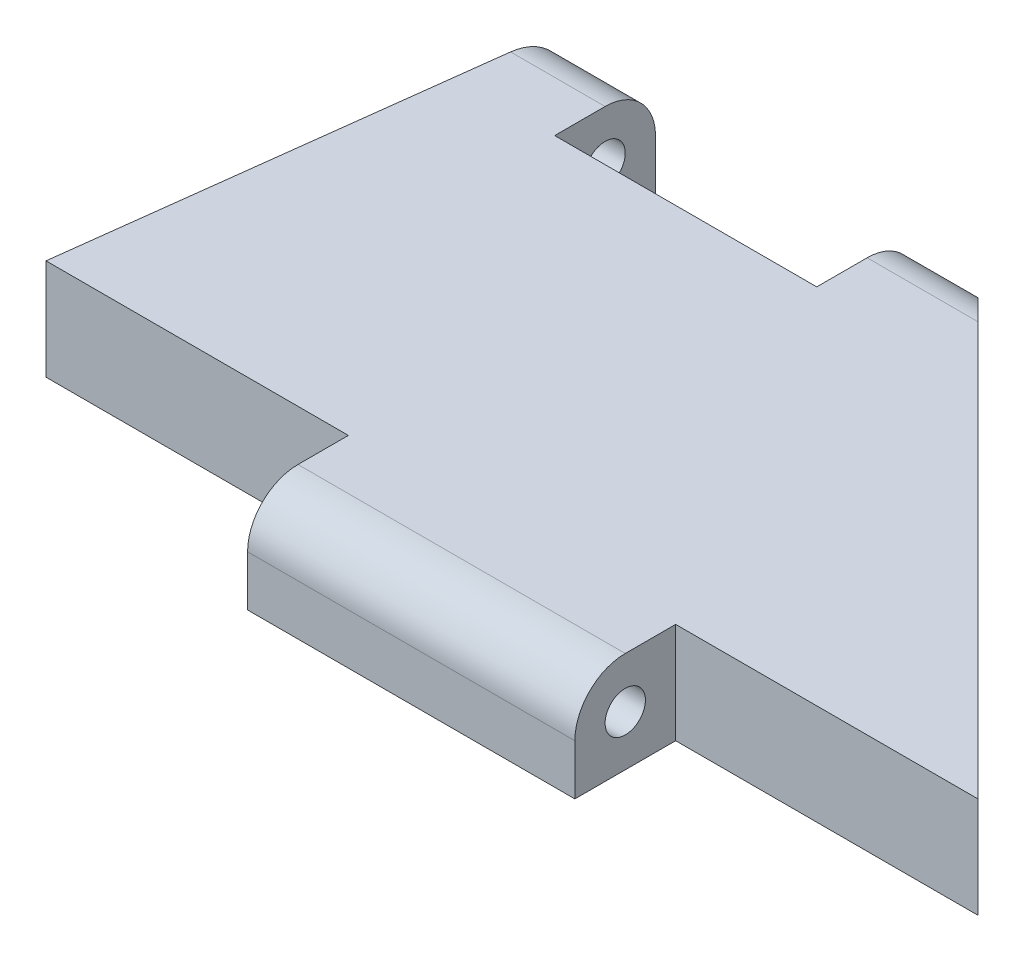
from build123d import *

# Parameters (mm, degrees)
BOSS_EXTRUDE1_DEPTH      = 6.35
SKETCH2_R                = 3.175
SKETCH2_R_2              = 1.27
BOSS_EXTRUDE2_DEPTH      = 32.213991
BOSS_EXTRUDE2_DEPTH_BACK = 26.506426
CUT_EXTRUDE1_START       = 32.213991
SKETCH2_7_R              = 3.175
SKETCH2_7_R_2            = 1.27
CUT_EXTRUDE1_DEPTH       = 19.05
CUT_EXTRUDE2_START       = -26.506426
SKETCH2_8_R              = 3.175
SKETCH2_8_R_2            = 1.27
CUT_EXTRUDE2_DEPTH       = 19.05
BOSS_EXTRUDE3_DEPTH      = 19.05
BOSS_EXTRUDE3_DEPTH_BACK = 24.13
CUT_EXTRUDE3_DEPTH       = 19.05
CUT_EXTRUDE4_START       = 3.81
SKETCH6_R                = 3.175
SKETCH6_R_2              = 1.27
CUT_EXTRUDE4_DEPTH       = 16.51
SKETCH6_4_R              = 1.27
CUT_EXTRUDE5_DEPTH       = 22.86


with BuildPart() as part:
    # Sketch1 → Boss-Extrude1 (new body)
    with BuildSketch(Plane(origin=(0, 0, 0), x_dir=(1, 0, 0), z_dir=(0, 1, 0))):
        Polygon((-26.506426074, 19.099553328), (32.213990648, 19.099553328), (9.353990648, 41.959553328), (-23.666009352, 41.959553328), align=None)
    extrude(amount=BOSS_EXTRUDE1_DEPTH)

    # Sketch2 → Boss-Extrude2 (add, two sides)
    with BuildSketch(Plane(origin=(0, 0, 0), x_dir=(0, 0, -1), z_dir=(1, 0, 0))) as boss_extrude2_sk:
        with BuildLine():
            ThreePointArc((19.099553328, 3.175), (18.169617358, 0.92993597), (15.924553328, 0))
            Line((15.924553328, 0), (19.099553328, 0))
            Line((19.099553328, 0), (19.099553328, 3.175))
        make_face()
        with BuildLine():
            ThreePointArc((15.924553328, 6.35), (18.169617358, 5.42006403), (19.099553328, 3.175))
            Line((19.099553328, 3.175), (19.099553328, 6.35))
            Line((19.099553328, 6.35), (15.924553328, 6.35))
        make_face()
        with Locations((15.924553328, 3.175)):
            Circle(SKETCH2_R)
        with Locations((15.924553328, 3.175)):
            Circle(SKETCH2_R_2, mode=Mode.SUBTRACT)
        with BuildLine():
            Line((12.749553328, 3.175), (12.749553328, 0))
            Line((12.749553328, 0), (15.924553328, 0))
            ThreePointArc((15.924553328, 0), (13.679489298, 0.92993597), (12.749553328, 3.175))
        make_face()
    extrude(amount=BOSS_EXTRUDE2_DEPTH)
    extrude(boss_extrude2_sk.sketch, amount=-BOSS_EXTRUDE2_DEPTH_BACK)

    # Sketch2_7 → Cut-Extrude1 (cut)
    with BuildSketch(Plane(origin=(0, 0, 0), x_dir=(0, 0, -1), z_dir=(1, 0, 0)).offset(CUT_EXTRUDE1_START)):
        with Locations((15.924553328, 3.175)):
            Circle(SKETCH2_7_R)
        with Locations((15.924553328, 3.175)):
            Circle(SKETCH2_7_R_2, mode=Mode.SUBTRACT)
        with BuildLine():
            ThreePointArc((19.099553328, 3.175), (18.169617358, 0.92993597), (15.924553328, 0))
            Line((15.924553328, 0), (19.099553328, 0))
            Line((19.099553328, 0), (19.099553328, 3.175))
        make_face()
        with BuildLine():
            Line((12.749553328, 3.175), (12.749553328, 0))
            Line((12.749553328, 0), (15.924553328, 0))
            ThreePointArc((15.924553328, 0), (13.679489298, 0.92993597), (12.749553328, 3.175))
        make_face()
        with BuildLine():
            ThreePointArc((15.924553328, 6.35), (18.169617358, 5.42006403), (19.099553328, 3.175))
            Line((19.099553328, 3.175), (19.099553328, 6.35))
            Line((19.099553328, 6.35), (15.924553328, 6.35))
        make_face()
    extrude(amount=-CUT_EXTRUDE1_DEPTH, mode=Mode.SUBTRACT)

    # Sketch2_8 → Cut-Extrude2 (cut)
    with BuildSketch(Plane(origin=(0, 0, 0), x_dir=(0, 0, -1), z_dir=(1, 0, 0)).offset(CUT_EXTRUDE2_START)):
        with Locations((15.924553328, 3.175)):
            Circle(SKETCH2_8_R)
        with Locations((15.924553328, 3.175)):
            Circle(SKETCH2_8_R_2, mode=Mode.SUBTRACT)
        with BuildLine():
            ThreePointArc((19.099553328, 3.175), (18.169617358, 0.92993597), (15.924553328, 0))
            Line((15.924553328, 0), (19.099553328, 0))
            Line((19.099553328, 0), (19.099553328, 3.175))
        make_face()
        with BuildLine():
            Line((12.749553328, 3.175), (12.749553328, 0))
            Line((12.749553328, 0), (15.924553328, 0))
            ThreePointArc((15.924553328, 0), (13.679489298, 0.92993597), (12.749553328, 3.175))
        make_face()
        with BuildLine():
            ThreePointArc((15.924553328, 6.35), (18.169617358, 5.42006403), (19.099553328, 3.175))
            Line((19.099553328, 3.175), (19.099553328, 6.35))
            Line((19.099553328, 6.35), (15.924553328, 6.35))
        make_face()
    extrude(amount=CUT_EXTRUDE2_DEPTH, mode=Mode.SUBTRACT)

    # Sketch5 → Boss-Extrude3 (add, two sides)
    with BuildSketch(Plane(origin=(0, 0, 0), x_dir=(0, 0, -1), z_dir=(1, 0, 0))) as boss_extrude3_sk:
        with BuildLine():
            Line((48.309553328, 0), (48.309553328, 3.175))
            ThreePointArc((48.309553328, 3.175), (47.379617358, 5.42006403), (45.134553328, 6.35))
            Line((45.134553328, 6.35), (41.959553328, 6.35))
            Line((41.959553328, 6.35), (41.959553328, 0))
            Line((41.959553328, 0), (48.309553328, 0))
        make_face()
    extrude(amount=BOSS_EXTRUDE3_DEPTH)
    extrude(boss_extrude3_sk.sketch, amount=-BOSS_EXTRUDE3_DEPTH_BACK)

    # Sketch3 → Cut-Extrude3 (cut)
    with BuildSketch(Plane(origin=(0, 6.35, 0), x_dir=(1, 0, 0), z_dir=(0, 1, 0))):
        Polygon((-23.666009352, 41.959553328), (-20.016630387, 71.330174364), (9.353990648, 41.959553328), (25.531438474, 33.85540027), (42.679810996, 71.330174364), (-40.952906467, 76.015398382), (-46.546209233, 30.999855332), align=None)
    extrude(amount=-CUT_EXTRUDE3_DEPTH, mode=Mode.SUBTRACT)

    # Sketch6 → Cut-Extrude4 (cut)
    with BuildSketch(Plane(origin=(3.003990648, 0, 0), x_dir=(0, 1, 0), z_dir=(-1, 0, 0)).offset(CUT_EXTRUDE4_START)):
        with Locations((3.175, 45.134553328)):
            Circle(SKETCH6_R)
        with Locations(Location((3.175, 45.134553328, 0), (0, 0, 270))):
            Circle(SKETCH6_R_2, mode=Mode.SUBTRACT)
        with BuildLine():
            ThreePointArc((3.175, 48.309553328), (5.42006403, 47.379617358), (6.35, 45.134553328))
            Line((6.35, 45.134553328), (6.35, 48.309553328))
            Line((6.35, 48.309553328), (3.175, 48.309553328))
        make_face()
        with BuildLine():
            Line((0, 48.309553328), (0, 45.134553328))
            ThreePointArc((0, 45.134553328), (0.92993597, 47.379617358), (3.175, 48.309553328))
            Line((3.175, 48.309553328), (0, 48.309553328))
        make_face()
        with BuildLine():
            Line((3.175, 41.959553328), (6.35, 41.959553328))
            Line((6.35, 41.959553328), (6.35, 45.134553328))
            ThreePointArc((6.35, 45.134553328), (5.42006403, 42.889489298), (3.175, 41.959553328))
        make_face()
        with BuildLine():
            Line((0, 41.959553328), (3.175, 41.959553328))
            ThreePointArc((3.175, 41.959553328), (0.92993597, 42.889489298), (0, 45.134553328))
            Line((0, 45.134553328), (0, 41.959553328))
        make_face()
    extrude(amount=CUT_EXTRUDE4_DEPTH, mode=Mode.SUBTRACT)

    # Sketch6_4 → Cut-Extrude5 (cut)
    with BuildSketch(Plane(origin=(3.003990648, 0, 0), x_dir=(0, 1, 0), z_dir=(-1, 0, 0))):
        with Locations(Location((3.175, 45.134553328, 0), (0, 0, 270))):
            Circle(SKETCH6_4_R)
    extrude(amount=CUT_EXTRUDE5_DEPTH, mode=Mode.SUBTRACT)


solid = part.part
